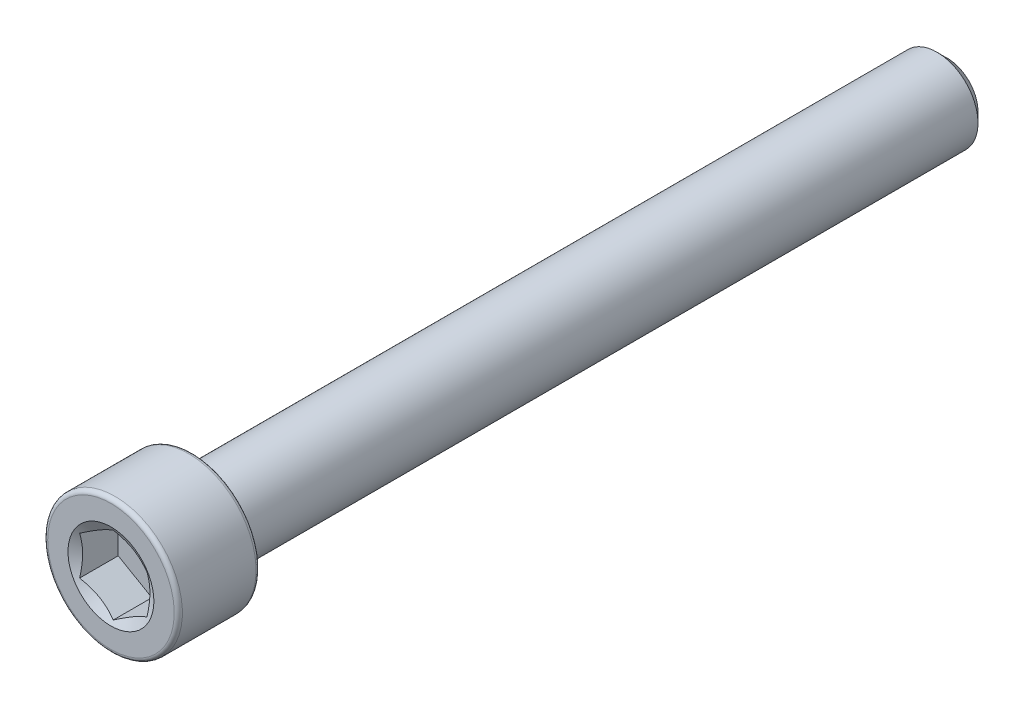
from build123d import *

# Parameters (mm, degrees)
CUT_EXTRUDE1_START = 24.638
CUT_EXTRUDE1_DEPTH = 2.413


with BuildPart() as part:
    # Sketch2 → Revolve1 (revolve)
    with BuildSketch(Plane(origin=(0, 0, 0), x_dir=(0, 0, -1), z_dir=(1, 0, 0)), mode=Mode.PRIVATE) as revolve1_sk:
        with BuildLine():
            Line((24.638, 0), (24.638, 1.8176875))
            Line((24.638, 1.8176875), (24.0426875, 2.413))
            Line((24.0426875, 2.413), (-19.812, 2.413))
            Line((-19.812, 2.413), (-19.812, 3.72745))
            ThreePointArc((-19.812, 3.72745), (-19.882675134, 3.898074866), (-20.0533, 3.96875))
            Line((-20.0533, 3.96875), (-24.3967, 3.96875))
            ThreePointArc((-24.3967, 3.96875), (-24.567324866, 3.898074866), (-24.638, 3.72745))
            Line((-24.638, 3.72745), (-24.638, 0))
            Line((-24.638, 0), (24.638, 0))
        make_face()
    revolve(revolve1_sk.sketch.rotate(Axis((0, 0, -24.638), (0, 0, 1)), 90), axis=Axis((0, 0, -24.638), (0, 0, 1)))

    # Sketch3 → Cut-Extrude1 (cut)
    with BuildSketch(Plane.XY.offset(CUT_EXTRUDE1_START)):
        Polygon((-1.984375, 1.14567944), (-1.984375, -1.14567944), (0, -2.291358881), (1.984375, -1.14567944), (1.984375, 1.14567944), (0, 2.291358881), align=None)
    extrude(amount=-CUT_EXTRUDE1_DEPTH, mode=Mode.SUBTRACT)

    # Cut-Extrude2 cone 1 section (through the dimple's axis) → Cut-Extrude2 (revolve, cut)
    with BuildSketch(Plane(origin=(0, 0, 24.638), x_dir=(0, -1, 0), z_dir=(1, 0, 0))):
        Polygon((0, 0), (2.530707401, 0), (0, 1.461104599), align=None)
    revolve(axis=Axis((0, 0, 24.638), (0, 0, -1)), mode=Mode.SUBTRACT)


solid = part.part
